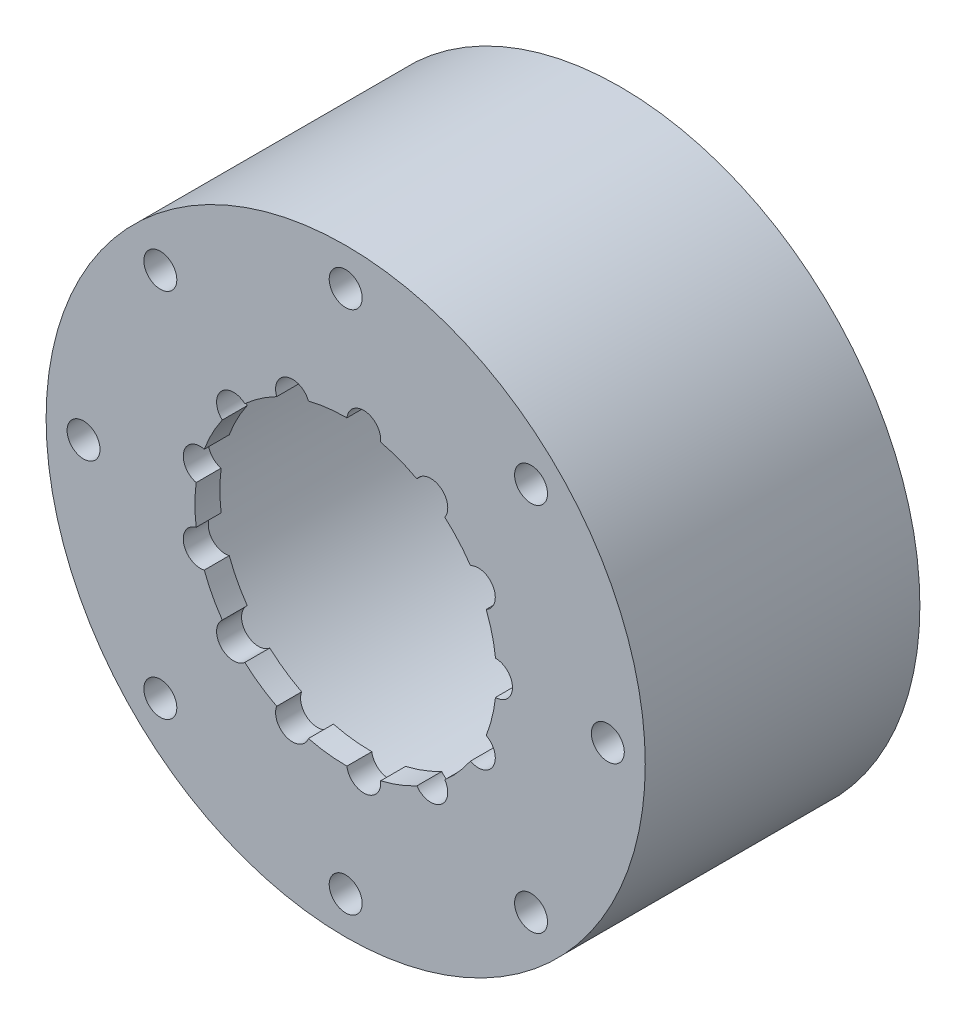
from build123d import *

# Parameters (mm, degrees)
SKETCH2_R            = 60
SKETCH2_R_2          = 45
BOSS_EXTRUDE2_DEPTH  = 25
SKETCH3_R            = 60
BOSS_EXTRUDE3_DEPTH  = 5
M6_CLEARANCE_HOLE1_D = 6.6


with BuildPart() as part:
    # Sketch2 → Boss-Extrude2 (new body, symmetric)
    with BuildSketch(Plane.XY):
        Circle(SKETCH2_R)
        Circle(SKETCH2_R_2, mode=Mode.SUBTRACT)
    extrude(amount=BOSS_EXTRUDE2_DEPTH, both=True)

    # Sketch3 → Boss-Extrude3 (add)
    with BuildSketch(Plane.XY.offset(25)):
        Circle(SKETCH3_R)
        with BuildLine():
            ThreePointArc((24.990710007, 16.9559551), (22.605024595, 20.026304279), (19.844624318, 22.764685055))
            ThreePointArc((19.844624318, 22.764685055), (18.973362541, 27.487661121), (14.248349522, 26.62751464))
            ThreePointArc((14.248349522, 26.62751464), (10.709067589, 28.237490529), (6.99226553, 29.379384316))
            ThreePointArc((6.99226553, 29.379384316), (4.025925121, 33.156476395), (0.241863872, 30.199031472))
            ThreePointArc((0.241863872, 30.199031472), (-3.640207744, 29.979807998), (-7.461937025, 29.263620689))
            ThreePointArc((-7.461937025, 29.263620689), (-11.843803227, 31.229542506), (-13.820029875, 26.852314132))
            ThreePointArc((-13.820029875, 26.852314132), (-17.155555351, 24.85411275), (-20.206699734, 22.443914227))
            ThreePointArc((-20.206699734, 22.443914227), (-25.000258989, 22.148296785), (-24.715921328, 17.35405523))
            ThreePointArc((-24.715921328, 17.35405523), (-26.740771975, 14.034639796), (-28.322351051, 10.482577495))
            ThreePointArc((-28.322351051, 10.482577495), (-32.429456702, 7.993143187), (-29.949693064, 3.880191413))
            ThreePointArc((-29.949693064, 3.880191413), (-30.2, 0), (-29.949693064, -3.880191413))
            ThreePointArc((-29.949693064, -3.880191413), (-32.429456702, -7.993143187), (-28.322351051, -10.482577495))
            ThreePointArc((-28.322351051, -10.482577495), (-26.740771975, -14.034639796), (-24.715921328, -17.35405523))
            ThreePointArc((-24.715921328, -17.35405523), (-25.000258989, -22.148296785), (-20.206699734, -22.443914227))
            ThreePointArc((-20.206699734, -22.443914227), (-17.155555351, -24.85411275), (-13.820029875, -26.852314132))
            ThreePointArc((-13.820029875, -26.852314132), (-11.843803227, -31.229542506), (-7.461937025, -29.263620689))
            ThreePointArc((-7.461937025, -29.263620689), (-3.640207744, -29.979807998), (0.241863872, -30.199031472))
            ThreePointArc((0.241863872, -30.199031472), (4.025925121, -33.156476395), (6.99226553, -29.379384316))
            ThreePointArc((6.99226553, -29.379384316), (10.709067589, -28.237490529), (14.248349522, -26.62751464))
            ThreePointArc((14.248349522, -26.62751464), (18.973362541, -27.487661121), (19.844624318, -22.764685055))
            ThreePointArc((19.844624318, -22.764685055), (22.605024595, -20.026304279), (24.990710007, -16.9559551))
            ThreePointArc((24.990710007, -16.9559551), (29.574231257, -15.521753946), (28.150818829, -10.934870793))
            ThreePointArc((28.150818829, -10.934870793), (29.322442886, -7.227333061), (30.008, -3.399990588))
            ThreePointArc((30.008, -3.399990588), (33.4, 0), (30.008, 3.399990588))
            ThreePointArc((30.008, 3.399990588), (29.322442886, 7.227333061), (28.150818829, 10.934870793))
            ThreePointArc((28.150818829, 10.934870793), (29.574231257, 15.521753946), (24.990710007, 16.9559551))
        make_face(mode=Mode.SUBTRACT)
    extrude(amount=BOSS_EXTRUDE3_DEPTH)

    # M6 Clearance Hole1 (through all)
    with Locations(Plane.XY.offset(30)):
        with Locations((-37.123106012, 37.123106012), (0, 52.5), (37.123106012, 37.123106012), (52.5, 0), (37.123106012, -37.123106012), (0, -52.5), (-37.123106012, -37.123106012), (-52.5, 0)):
            Hole(M6_CLEARANCE_HOLE1_D / 2)


solid = part.part
